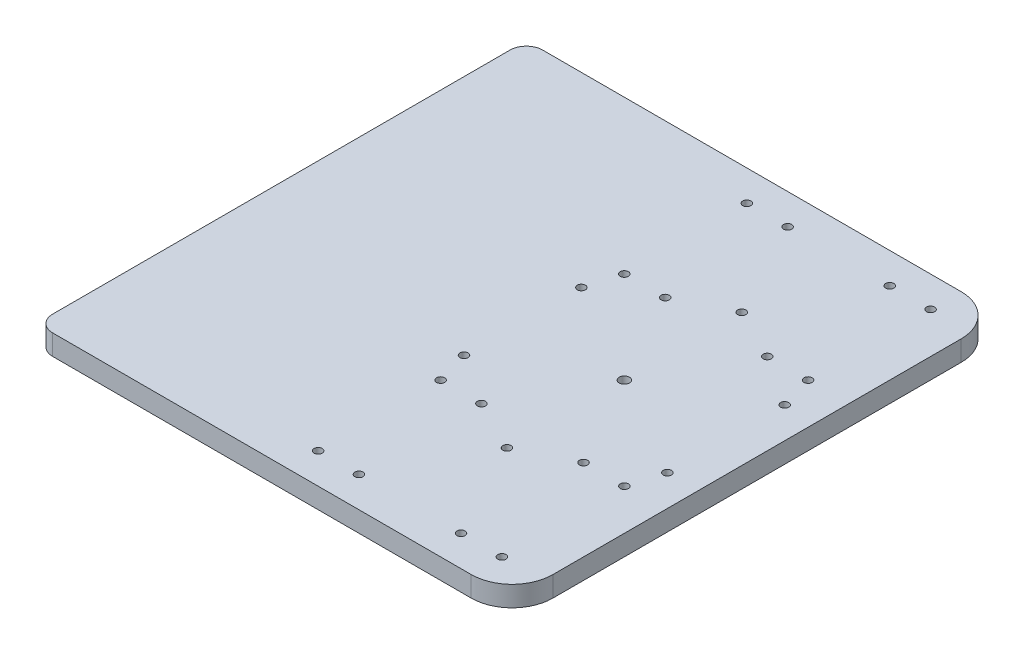
from build123d import *

# Parameters (mm, degrees)
SKETCH1_R           = 2
SKETCH1_R_2         = 2.5
BOSS_EXTRUDE1_DEPTH = 10
SKETCH3_W           = 240
SKETCH3_H           = 10
CUT_EXTRUDE1_DEPTH  = 45
FILLET1_R           = 8


with BuildPart() as part:
    # Sketch1 → Boss-Extrude1 (new body)
    with BuildSketch(Plane(origin=(0, 0, 0), x_dir=(1, 0, 0), z_dir=(0, 1, 0))):
        with BuildLine():
            Line((-193, 120), (45, 120))
            ThreePointArc((45, 120), (59.142135624, 114.142135624), (65, 100))
            Line((65, 100), (65, -100))
            ThreePointArc((65, -100), (59.142135624, -114.142135624), (45, -120))
            Line((45, -120), (-193, -120))
            ThreePointArc((-193, -120), (-207.142135624, -114.142135624), (-213, -100))
            Line((-213, -100), (-213, 100))
            ThreePointArc((-213, 100), (-207.142135624, 114.142135624), (-193, 120))
        make_face()
        with Locations((0, -57.5)):
            Circle(SKETCH1_R, mode=Mode.SUBTRACT)
        with Locations((-49.796460718, -28.75)):
            Circle(SKETCH1_R, mode=Mode.SUBTRACT)
        with Locations((-49.796460718, 28.75)):
            Circle(SKETCH1_R, mode=Mode.SUBTRACT)
        with Locations((0, 57.5)):
            Circle(SKETCH1_R, mode=Mode.SUBTRACT)
        with Locations((49.796460718, 28.75)):
            Circle(SKETCH1_R, mode=Mode.SUBTRACT)
        with Locations((49.796460718, -28.75)):
            Circle(SKETCH1_R, mode=Mode.SUBTRACT)
        Circle(SKETCH1_R_2, mode=Mode.SUBTRACT)
        with Locations((-45, 105)):
            Circle(SKETCH1_R, mode=Mode.SUBTRACT)
        with Locations((-25, 105)):
            Circle(SKETCH1_R, mode=Mode.SUBTRACT)
        with Locations((25, 105)):
            Circle(SKETCH1_R, mode=Mode.SUBTRACT)
        with Locations((45, 105)):
            Circle(SKETCH1_R, mode=Mode.SUBTRACT)
        with Locations((-45, 45)):
            Circle(SKETCH1_R, mode=Mode.SUBTRACT)
        with Locations((-25, 45)):
            Circle(SKETCH1_R, mode=Mode.SUBTRACT)
        with Locations((25, 45)):
            Circle(SKETCH1_R, mode=Mode.SUBTRACT)
        with Locations((45, 45)):
            Circle(SKETCH1_R, mode=Mode.SUBTRACT)
        with Locations((-45, -45)):
            Circle(SKETCH1_R, mode=Mode.SUBTRACT)
        with Locations((-25, -45)):
            Circle(SKETCH1_R, mode=Mode.SUBTRACT)
        with Locations((25, -45)):
            Circle(SKETCH1_R, mode=Mode.SUBTRACT)
        with Locations((45, -45)):
            Circle(SKETCH1_R, mode=Mode.SUBTRACT)
        with Locations((45, -105)):
            Circle(SKETCH1_R, mode=Mode.SUBTRACT)
        with Locations((25, -105)):
            Circle(SKETCH1_R, mode=Mode.SUBTRACT)
        with Locations((-25, -105)):
            Circle(SKETCH1_R, mode=Mode.SUBTRACT)
        with Locations((-45, -105)):
            Circle(SKETCH1_R, mode=Mode.SUBTRACT)
    extrude(amount=BOSS_EXTRUDE1_DEPTH)

    # Sketch3 → Cut-Extrude1 (cut)
    with BuildSketch(Plane.ZY.offset(213)):
        with Locations((0, 5)):
            Rectangle(SKETCH3_W, SKETCH3_H)
    extrude(amount=-CUT_EXTRUDE1_DEPTH, mode=Mode.SUBTRACT)

    # Fillet1
    fillet1_edges = [part.edges().sort_by_distance(p)[0] for p in [
        (-168, 5, 120),
        (-168, 5, -120),
    ]]
    fillet(fillet1_edges, radius=FILLET1_R)


solid = part.part
